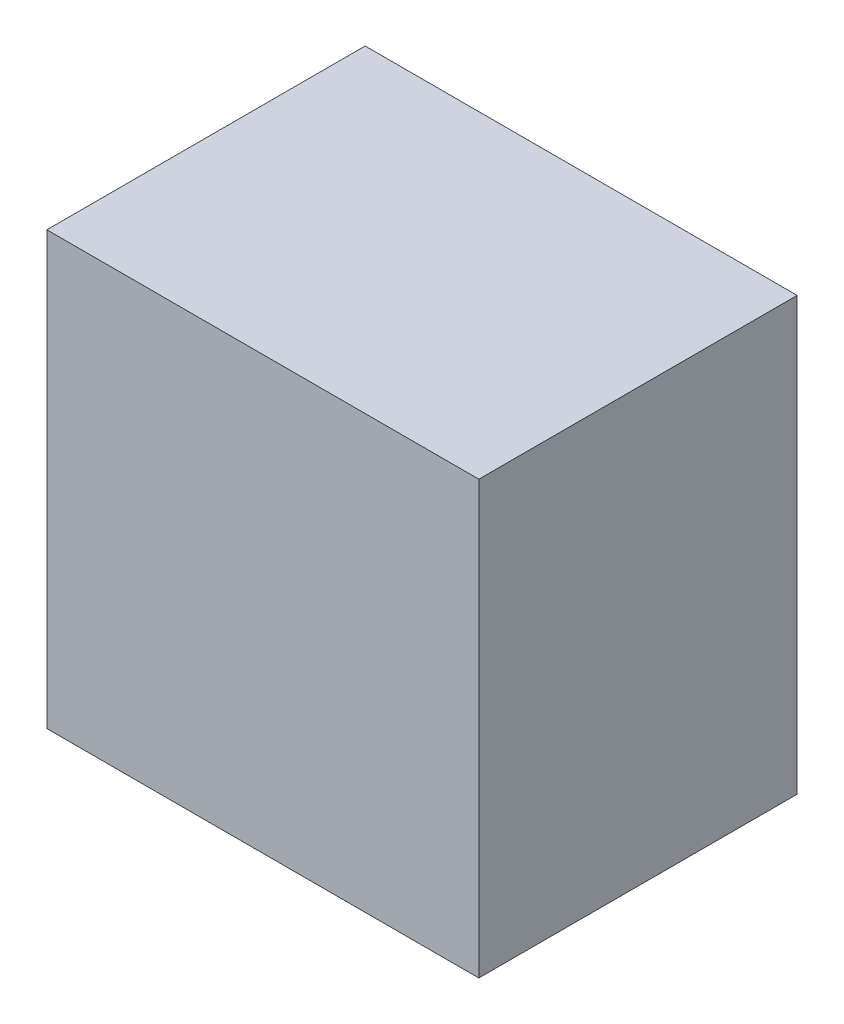
from build123d import *

# Parameters (mm, degrees)
ESQUISSE1_W        = 380
ESQUISSE1_H        = 380
ESQUISSE1_W_2      = 340
ESQUISSE1_H_2      = 340
BOSS_EXTRU_1_DEPTH = 260
ESQUISSE2_W        = 380
ESQUISSE2_H        = 380
BOSS_EXTRU_2_DEPTH = 20


with BuildPart() as part:
    # Esquisse1 → Boss.-Extru.1 (new body)
    with BuildSketch(Plane.XY):
        Rectangle(ESQUISSE1_W, ESQUISSE1_H)
        Rectangle(ESQUISSE1_W_2, ESQUISSE1_H_2, mode=Mode.SUBTRACT)
    extrude(amount=BOSS_EXTRU_1_DEPTH)

    # Esquisse2 → Boss.-Extru.2 (add)
    with BuildSketch(Plane.XY.offset(260)):
        Rectangle(ESQUISSE2_W, ESQUISSE2_H)
    extrude(amount=BOSS_EXTRU_2_DEPTH)


solid = part.part
